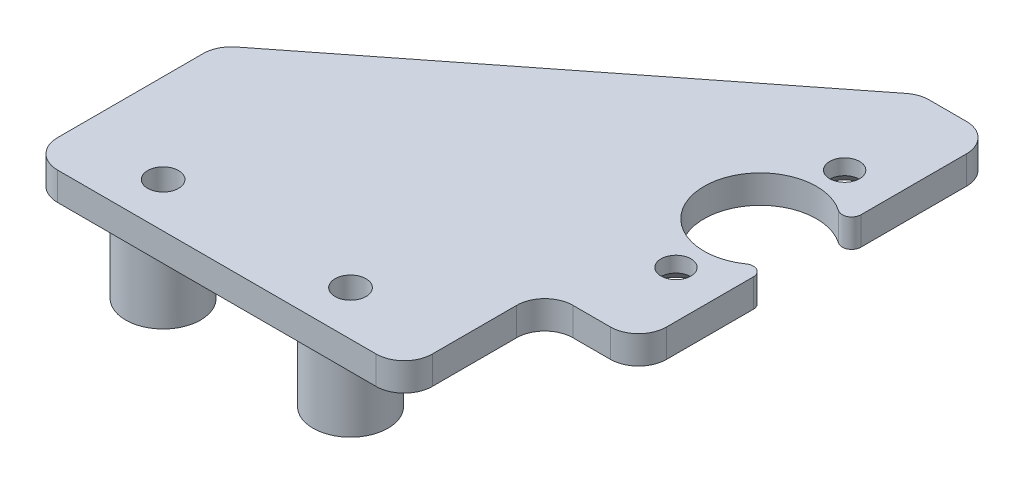
from build123d import *

# Parameters (mm, degrees)
ESBO_O1_R                  = 1.6
RESSALTO_EXTRUS_O10_DEPTH  = 3
FILETE2_R                  = 1
CHANFRO1_SIZE              = 1.35
ESBO_O5_W                  = 50
ESBO_O5_H                  = 13
RESSALTO_EXTRUS_O13_DEPTH  = 3
ESBO_O7_R                  = 1.65
CORTE_EXTRUS_O1_DEPTH      = 1
CORTE_EXTRUS_O1_DEPTH_BACK = 4
ESBO_O8_W                  = 10
ESBO_O8_H                  = 15
CORTE_EXTRUS_O2_DEPTH      = 4
FILETE3_R                  = 3
ESBO_O9_R                  = 4
RESSALTO_EXTRUS_O14_DEPTH  = 8
ESBO_O10_R                 = 1.65
CORTE_EXTRUS_O5_DEPTH      = 9


with BuildPart() as part:
    # Esboço1 → Ressalto-extrusão10 (new body)
    with BuildSketch(Plane(origin=(0, 0, 0), x_dir=(1, 0, 0), z_dir=(0, 1, 0))):
        with BuildLine():
            Line((25, 20), (-25, 20))
            Line((-25, 20), (-25, -20))
            Line((-25, -20), (25, -20))
            Line((25, -20), (25, -3.31662479))
            ThreePointArc((25, -3.31662479), (14, 0), (25, 3.31662479))
            Line((25, 3.31662479), (25, 20))
        make_face()
        with Locations((20, -9)):
            Circle(ESBO_O1_R, mode=Mode.SUBTRACT)
        with Locations((20, 9)):
            Circle(ESBO_O1_R, mode=Mode.SUBTRACT)
    extrude(amount=RESSALTO_EXTRUS_O10_DEPTH)

    # Filete2
    filete2_edges = [part.edges().sort_by_distance(p)[0] for p in [
        (25, 1.5, 3.31662479),
        (25, 1.5, -3.31662479),
    ]]
    fillet(filete2_edges, radius=FILETE2_R)

    # Chanfro1
    chanfro1_edges = [part.edges().sort_by_distance(p)[0] for p in [
        (18.4, 0, -9),
        (18.4, 0, 9),
    ]]
    chamfer(chanfro1_edges, length=CHANFRO1_SIZE)

    # Esboço5 → Ressalto-extrusão13 (add)
    with BuildSketch(Plane.XZ):
        with Locations((0, 26.5)):
            Rectangle(ESBO_O5_W, ESBO_O5_H)
    extrude(amount=-RESSALTO_EXTRUS_O13_DEPTH)

    # Esboço7 → Corte-extrusão1 (cut, two sides)
    with BuildSketch(Plane.XZ) as corte_extrus_o1_sk:
        with Locations((-15.5, 28.234562647)):
            Circle(ESBO_O7_R)
        with Locations((4.5, 28.234562647)):
            Circle(ESBO_O7_R)
    extrude(amount=CORTE_EXTRUS_O1_DEPTH, mode=Mode.SUBTRACT)
    extrude(corte_extrus_o1_sk.sketch, amount=-CORTE_EXTRUS_O1_DEPTH_BACK, mode=Mode.SUBTRACT)

    # Esboço8 → Corte-extrusão2 (cut, through all)
    with BuildSketch(Plane.XZ):
        Polygon((-25, -20), (-25, 13), (17, -20), align=None)
        with Locations((20, 25.5)):
            Rectangle(ESBO_O8_W, ESBO_O8_H)
    extrude(amount=-CORTE_EXTRUS_O2_DEPTH, mode=Mode.SUBTRACT)

    # Filete3
    filete3_edges = [part.edges().sort_by_distance(p)[0] for p in [
        (25, 1.5, -20),
        (-25, 1.5, 33),
        (-25, 1.5, 13),
        (17, 1.5, -20),
        (15, 1.5, 18),
        (15, 1.5, 33),
        (25, 1.5, 18),
    ]]
    fillet(filete3_edges, radius=FILETE3_R)

    # Esboço9 → Ressalto-extrusão14 (add)
    with BuildSketch(Plane.XZ):
        with Locations((-15.5, 28.234562647)):
            Circle(ESBO_O9_R)
        with Locations((4.5, 28.234562647)):
            Circle(ESBO_O9_R)
        with Locations((-5.5, 10.234562647)):
            Circle(ESBO_O9_R)
    extrude(amount=RESSALTO_EXTRUS_O14_DEPTH)

    # Esboço10 → Corte-extrusão5 (cut, through all)
    with BuildSketch(Plane.XZ):
        with Locations((-15.5, 28.234562647)):
            Circle(ESBO_O10_R)
        with Locations((4.5, 28.234562647)):
            Circle(ESBO_O10_R)
    extrude(amount=CORTE_EXTRUS_O5_DEPTH, mode=Mode.SUBTRACT)


solid = part.part
